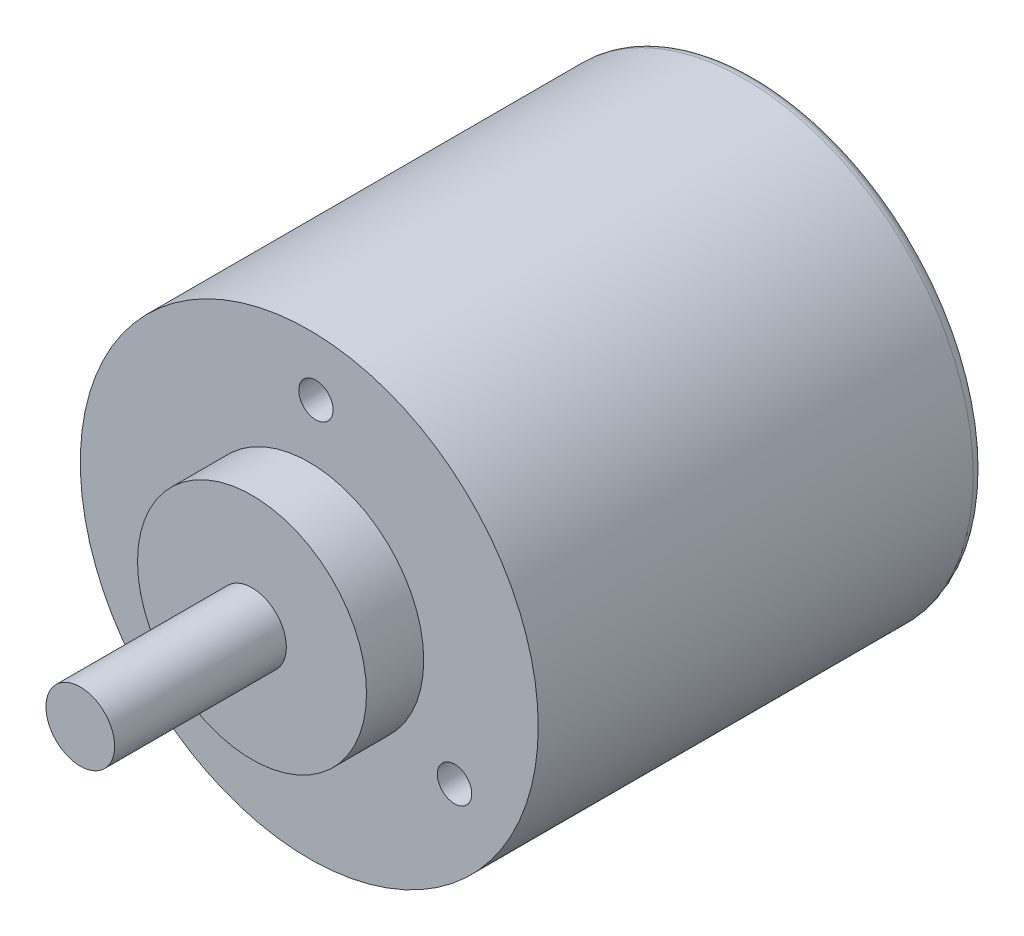
from build123d import *

# Parameters (mm, degrees)
SKETCH1_R           = 20
BOSS_EXTRUDE1_DEPTH = 39
SKETCH2_R           = 10
BOSS_EXTRUDE2_DEPTH = 5
SKETCH3_R           = 3
BOSS_EXTRUDE3_DEPTH = 15
FILLET1_R           = 1
SKETCH4_R           = 1.5
CUT_EXTRUDE1_DEPTH  = 5
CIRPATTERN1_COUNT   = 3


with BuildPart() as part:
    # Sketch1 → Boss-Extrude1 (new body)
    with BuildSketch(Plane.XY):
        Circle(SKETCH1_R)
    extrude(amount=BOSS_EXTRUDE1_DEPTH)

    # Sketch2 → Boss-Extrude2 (add)
    with BuildSketch(Plane.XY.offset(39)):
        Circle(SKETCH2_R)
    extrude(amount=BOSS_EXTRUDE2_DEPTH)

    # Sketch3 → Boss-Extrude3 (add)
    with BuildSketch(Plane.XY.offset(44)):
        Circle(SKETCH3_R)
    extrude(amount=BOSS_EXTRUDE3_DEPTH)

    # Fillet1
    fillet1_edges = [part.edges().sort_by_distance(p)[0] for p in [
        (-20, 0, 0),
    ]]
    fillet(fillet1_edges, radius=FILLET1_R)

    # Sketch4 → Cut-Extrude1 (cut)
    with BuildSketch(Plane.XY.offset(39)):
        with Locations((0.580678207, 14.988756213)):
            Circle(SKETCH4_R)
    cut_extrude1 = extrude(amount=-CUT_EXTRUDE1_DEPTH, mode=Mode.SUBTRACT)

    # CirPattern1: Cut-Extrude1 ×3 about axis
    cirpattern1_axis = Axis((0, 0, 0), (0, 0, 1))
    for i in range(1, CIRPATTERN1_COUNT):
        add(cut_extrude1.rotate(cirpattern1_axis, i * 360 / CIRPATTERN1_COUNT), mode=Mode.SUBTRACT)


solid = part.part
